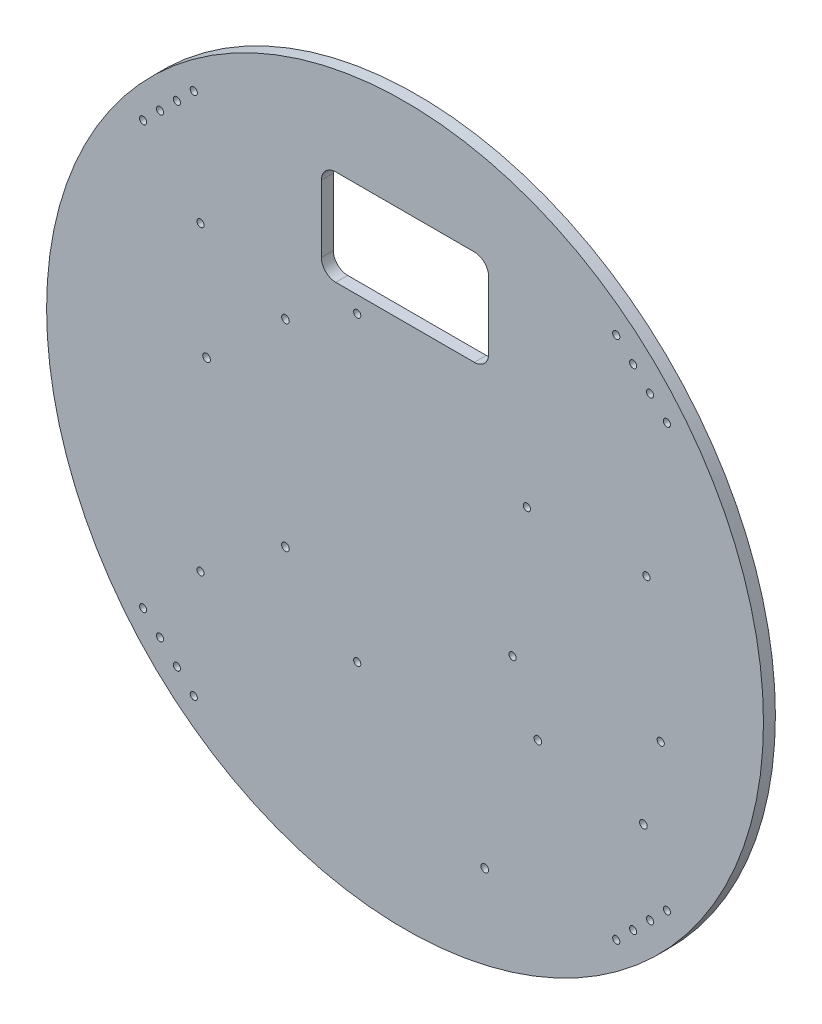
from build123d import *

# Parameters (mm, degrees)
ESQUISSE5_R                       = 150
ESQUISSE5_R_2                     = 1.6
BASE_DEPTH                        = 5
ESQUISSE8_R                       = 1.5
FIXATION_CRAN_DEPTH               = 6
ESQUISSE9_R                       = 1.5
FIXATION_LIDAR_DEPTH              = 6
ESQUISSE7_W                       = 70
ESQUISSE7_H                       = 40
EXTRUSION_PASSAGE_DE_CABLES_DEPTH = 5
CONG_1_R                          = 6
ESQUISSE10_R                      = 1.5
EXTRUSION_FIXATION_PAROI_DEPTH    = 6
ENL_V_MAT_EXTRU_1_REACH           = 7
ESQUISSE11_R                      = 1.5


with BuildPart() as part:
    # Esquisse5 → base (new body)
    with BuildSketch(Plane.XY):
        Circle(ESQUISSE5_R)
        with Locations((99.73919487, -62.04957211)):
            Circle(ESQUISSE5_R_2, mode=Mode.SUBTRACT)
        with Locations((55.59658934, -53.636417112)):
            Circle(ESQUISSE5_R_2, mode=Mode.SUBTRACT)
        with Locations((33.380811026, -111.152193156)):
            Circle(ESQUISSE5_R_2, mode=Mode.SUBTRACT)
        with Locations((-50.043705329, -36.418231474)):
            Circle(ESQUISSE5_R_2, mode=Mode.SUBTRACT)
        with Locations((-83.063705329, 15.651768526)):
            Circle(ESQUISSE5_R_2, mode=Mode.SUBTRACT)
        with Locations((-50.043705329, 46.131768526)):
            Circle(ESQUISSE5_R_2, mode=Mode.SUBTRACT)
    extrude(amount=BASE_DEPTH)

    # Esquisse8 → fixation écran (cut, through all)
    with BuildSketch(Plane.XY.offset(5)):
        with Locations((-85.6, 63.115)):
            Circle(ESQUISSE8_R)
        with Locations((-20, 63.115)):
            Circle(ESQUISSE8_R)
        with Locations((-85.6, -63.115)):
            Circle(ESQUISSE8_R)
        with Locations((-20, -63.115)):
            Circle(ESQUISSE8_R)
    extrude(amount=-FIXATION_CRAN_DEPTH, mode=Mode.SUBTRACT)

    # Esquisse9 → fixation lidar (cut, through all)
    with BuildSketch(Plane.XY.offset(5)):
        with Locations((45, -28.5)):
            Circle(ESQUISSE9_R)
        with Locations((107, -28.5)):
            Circle(ESQUISSE9_R)
        with Locations((101, 28.5)):
            Circle(ESQUISSE9_R)
        with Locations((51, 28.5)):
            Circle(ESQUISSE9_R)
    extrude(amount=-FIXATION_LIDAR_DEPTH, mode=Mode.SUBTRACT)

    # Esquisse7 → extrusion passage de cables (cut)
    with BuildSketch(Plane.XY.offset(5)):
        with Locations((0, 90)):
            Rectangle(ESQUISSE7_W, ESQUISSE7_H)
    extrude(amount=-EXTRUSION_PASSAGE_DE_CABLES_DEPTH, mode=Mode.SUBTRACT)

    # Congé1
    cong_1_edges = [part.edges().sort_by_distance(p)[0] for p in [
        (-35, 70, 2.5),
        (-35, 110, 2.5),
        (35, 110, 2.5),
        (35, 70, 2.5),
    ]]
    fillet(cong_1_edges, radius=CONG_1_R)

    # Esquisse10 → extrusion fixation paroi (cut, through all)
    with BuildSketch(Plane.XY.offset(5)):
        with Locations((-102.530483272, 95.45941546)):
            Circle(ESQUISSE10_R)
        with Locations((-95.45941546, 102.530483272)):
            Circle(ESQUISSE10_R)
        with Locations((95.45941546, 102.530483272)):
            Circle(ESQUISSE10_R)
        with Locations((102.530483272, 95.45941546)):
            Circle(ESQUISSE10_R)
        with Locations((102.530483272, -95.45941546)):
            Circle(ESQUISSE10_R)
        with Locations((95.45941546, -102.530483272)):
            Circle(ESQUISSE10_R)
        with Locations((-95.45941546, -102.530483272)):
            Circle(ESQUISSE10_R)
        with Locations((-102.530483272, -95.45941546)):
            Circle(ESQUISSE10_R)
    extrude(amount=-EXTRUSION_FIXATION_PAROI_DEPTH, mode=Mode.SUBTRACT)

    # Esquisse11 → Enlèv. mat.-Extru.1 (cut, up to next)
    with BuildSketch(Plane.XY.offset(5), mode=Mode.PRIVATE) as enl_v_mat_extru_1_sk1:
        with Locations((-88.388347648, 109.601551084)):
            Circle(ESQUISSE11_R)
    enl_v_mat_extru_1_tool1 = extrude(enl_v_mat_extru_1_sk1.sketch, amount=-ENL_V_MAT_EXTRU_1_REACH, mode=Mode.PRIVATE) & part.part
    add(enl_v_mat_extru_1_tool1.solids().sort_by_distance((-88.388348, 109.601551, 5))[0], mode=Mode.SUBTRACT)
    # Esquisse11 → Enlèv. mat.-Extru.1 (cut, up to next)
    with BuildSketch(Plane.XY.offset(5), mode=Mode.PRIVATE) as enl_v_mat_extru_1_sk2:
        with Locations((-109.601551084, 88.388347648)):
            Circle(ESQUISSE11_R)
    enl_v_mat_extru_1_tool2 = extrude(enl_v_mat_extru_1_sk2.sketch, amount=-ENL_V_MAT_EXTRU_1_REACH, mode=Mode.PRIVATE) & part.part
    add(enl_v_mat_extru_1_tool2.solids().sort_by_distance((-109.601551, 88.388348, 5))[0], mode=Mode.SUBTRACT)
    # Esquisse11 → Enlèv. mat.-Extru.1 (cut, up to next)
    with BuildSketch(Plane.XY.offset(5), mode=Mode.PRIVATE) as enl_v_mat_extru_1_sk3:
        with Locations((-109.601551084, -88.388347648)):
            Circle(ESQUISSE11_R)
    enl_v_mat_extru_1_tool3 = extrude(enl_v_mat_extru_1_sk3.sketch, amount=-ENL_V_MAT_EXTRU_1_REACH, mode=Mode.PRIVATE) & part.part
    add(enl_v_mat_extru_1_tool3.solids().sort_by_distance((-109.601551, -88.388348, 5))[0], mode=Mode.SUBTRACT)
    # Esquisse11 → Enlèv. mat.-Extru.1 (cut, up to next)
    with BuildSketch(Plane.XY.offset(5), mode=Mode.PRIVATE) as enl_v_mat_extru_1_sk4:
        with Locations((-88.388347648, -109.601551084)):
            Circle(ESQUISSE11_R)
    enl_v_mat_extru_1_tool4 = extrude(enl_v_mat_extru_1_sk4.sketch, amount=-ENL_V_MAT_EXTRU_1_REACH, mode=Mode.PRIVATE) & part.part
    add(enl_v_mat_extru_1_tool4.solids().sort_by_distance((-88.388348, -109.601551, 5))[0], mode=Mode.SUBTRACT)
    # Esquisse11 → Enlèv. mat.-Extru.1 (cut, up to next)
    with BuildSketch(Plane.XY.offset(5), mode=Mode.PRIVATE) as enl_v_mat_extru_1_sk5:
        with Locations((88.388347648, -109.601551084)):
            Circle(ESQUISSE11_R)
    enl_v_mat_extru_1_tool5 = extrude(enl_v_mat_extru_1_sk5.sketch, amount=-ENL_V_MAT_EXTRU_1_REACH, mode=Mode.PRIVATE) & part.part
    add(enl_v_mat_extru_1_tool5.solids().sort_by_distance((88.388348, -109.601551, 5))[0], mode=Mode.SUBTRACT)
    # Esquisse11 → Enlèv. mat.-Extru.1 (cut, up to next)
    with BuildSketch(Plane.XY.offset(5), mode=Mode.PRIVATE) as enl_v_mat_extru_1_sk6:
        with Locations((109.601551084, -88.388347648)):
            Circle(ESQUISSE11_R)
    enl_v_mat_extru_1_tool6 = extrude(enl_v_mat_extru_1_sk6.sketch, amount=-ENL_V_MAT_EXTRU_1_REACH, mode=Mode.PRIVATE) & part.part
    add(enl_v_mat_extru_1_tool6.solids().sort_by_distance((109.601551, -88.388348, 5))[0], mode=Mode.SUBTRACT)
    # Esquisse11 → Enlèv. mat.-Extru.1 (cut, up to next)
    with BuildSketch(Plane.XY.offset(5), mode=Mode.PRIVATE) as enl_v_mat_extru_1_sk7:
        with Locations((109.601551084, 88.388347648)):
            Circle(ESQUISSE11_R)
    enl_v_mat_extru_1_tool7 = extrude(enl_v_mat_extru_1_sk7.sketch, amount=-ENL_V_MAT_EXTRU_1_REACH, mode=Mode.PRIVATE) & part.part
    add(enl_v_mat_extru_1_tool7.solids().sort_by_distance((109.601551, 88.388348, 5))[0], mode=Mode.SUBTRACT)
    # Esquisse11 → Enlèv. mat.-Extru.1 (cut, up to next)
    with BuildSketch(Plane.XY.offset(5), mode=Mode.PRIVATE) as enl_v_mat_extru_1_sk8:
        with Locations((88.388347648, 109.601551084)):
            Circle(ESQUISSE11_R)
    enl_v_mat_extru_1_tool8 = extrude(enl_v_mat_extru_1_sk8.sketch, amount=-ENL_V_MAT_EXTRU_1_REACH, mode=Mode.PRIVATE) & part.part
    add(enl_v_mat_extru_1_tool8.solids().sort_by_distance((88.388348, 109.601551, 5))[0], mode=Mode.SUBTRACT)


solid = part.part
